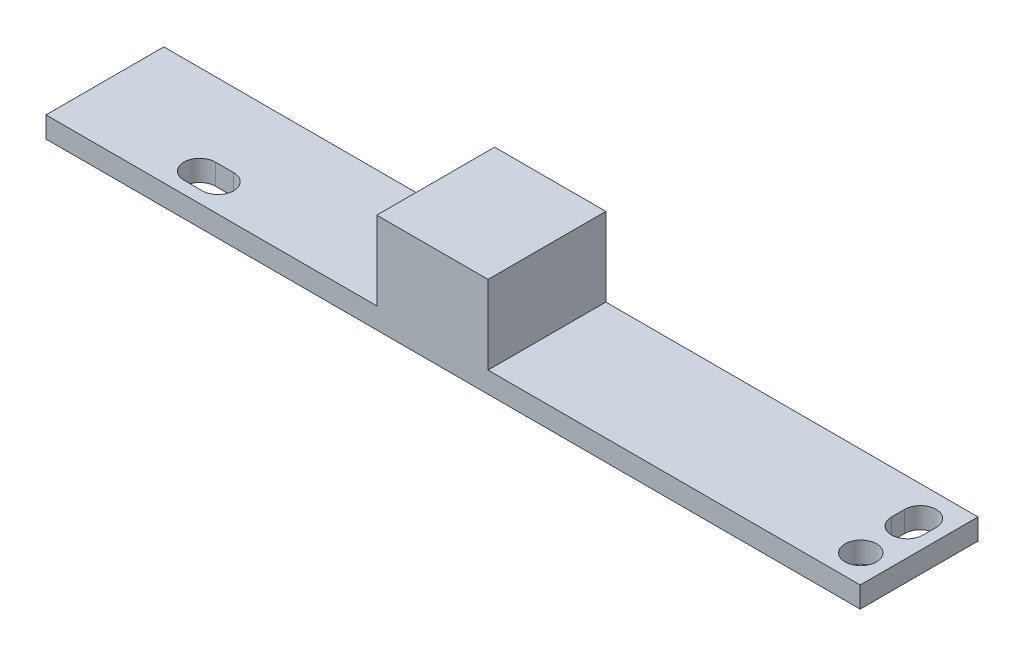
from build123d import *

# Parameters (mm, degrees)
SKETCH1_W           = 62.2
SKETCH1_H           = 9
BOSS_EXTRUDE1_DEPTH = 1.6
SKETCH2_R           = 1.2
CUT_EXTRUDE1_DEPTH  = 2.6
SKETCH3_W           = 8.5
SKETCH3_H           = 9
BOSS_EXTRUDE2_DEPTH = 6


with BuildPart() as part:
    # Sketch1 → Boss-Extrude1 (new body)
    with BuildSketch(Plane(origin=(0, 0, 0), x_dir=(1, 0, 0), z_dir=(0, 1, 0))):
        with Locations((31.1, 4.5)):
            Rectangle(SKETCH1_W, SKETCH1_H)
    extrude(amount=BOSS_EXTRUDE1_DEPTH)

    # Sketch2 → Cut-Extrude1 (cut, through all)
    with BuildSketch(Plane(origin=(0, 1.6, 0), x_dir=(1, 0, 0), z_dir=(0, 1, 0))):
        with Locations((60.098236825, 2.147164508)):
            Circle(SKETCH2_R)
        with BuildLine():
            Line((9.591628176, 3.347164508), (10.991628176, 3.347164508))
            ThreePointArc((10.991628176, 3.347164508), (12.191628176, 2.147164508), (10.991628176, 0.947164508))
            Line((10.991628176, 0.947164508), (9.591628176, 0.947164508))
            ThreePointArc((9.591628176, 0.947164508), (8.391628176, 2.147164508), (9.591628176, 3.347164508))
        make_face()
        with BuildLine():
            Line((61.298236825, 6.7), (61.298236825, 5.7))
            ThreePointArc((61.298236825, 5.7), (60.098236825, 4.5), (58.898236825, 5.7))
            Line((58.898236825, 5.7), (58.898236825, 6.7))
            ThreePointArc((58.898236825, 6.7), (60.098236825, 7.9), (61.298236825, 6.7))
        make_face()
    extrude(amount=-CUT_EXTRUDE1_DEPTH, mode=Mode.SUBTRACT)

    # Sketch3 → Boss-Extrude2 (add)
    with BuildSketch(Plane(origin=(0, 1.6, 0), x_dir=(1, 0, 0), z_dir=(0, 1, 0))):
        with Locations((29.52, 4.5)):
            Rectangle(SKETCH3_W, SKETCH3_H)
    extrude(amount=BOSS_EXTRUDE2_DEPTH)


solid = part.part
